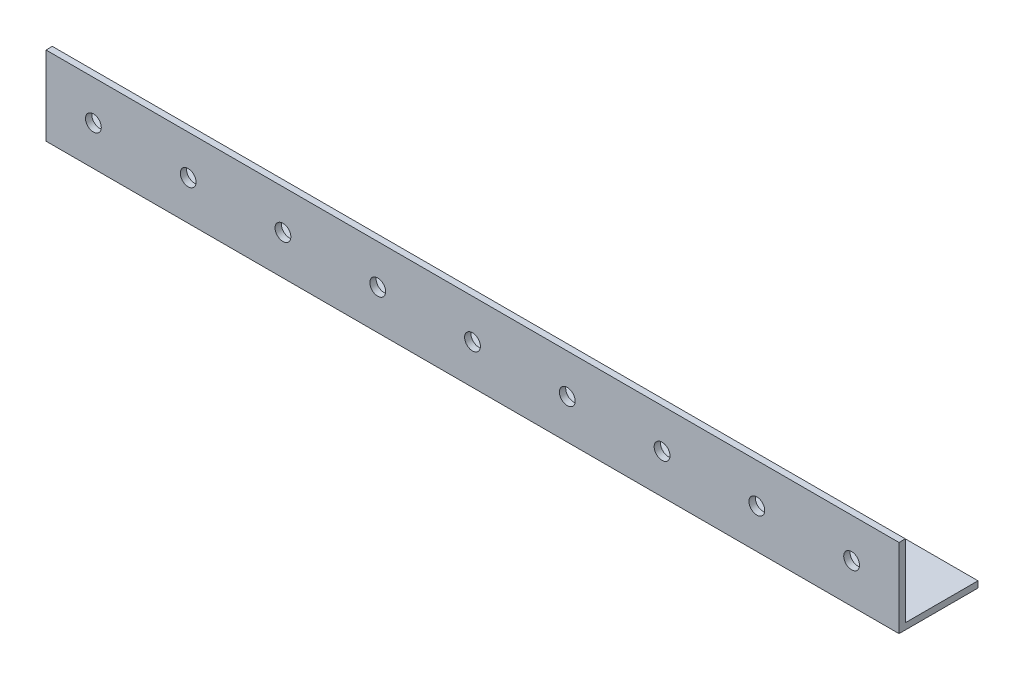
from build123d import *

# Parameters (mm, degrees)
EXTRUDE_1_DEPTH     = 540
SKETCH_2_R          = 5
CUT_EXTRUDE_1_DEPTH = 51
SKETCH_3_R          = 5
CUT_EXTRUDE_2_DEPTH = 51


with BuildPart() as part:
    # Эскиз1 → Вытянуть-Тонкостенный1 (new body)
    with BuildSketch(Plane(origin=(0, 0, 0), x_dir=(0, 0, -1), z_dir=(1, 0, 0))):
        Polygon((50, 0), (0, 0), (0, 50), (4, 50), (4, 4), (50, 4), align=None)
    extrude(amount=EXTRUDE_1_DEPTH)

    # Эскиз2 → Вырез-Вытянуть1 (cut, through all)
    with BuildSketch(Plane.XY):
        with Locations((30, 25)):
            Circle(SKETCH_2_R)
        with Locations((90, 25)):
            Circle(SKETCH_2_R)
        with Locations((150, 25)):
            Circle(SKETCH_2_R)
        with Locations((210, 25)):
            Circle(SKETCH_2_R)
        with Locations((270, 25)):
            Circle(SKETCH_2_R)
        with Locations((330, 25)):
            Circle(SKETCH_2_R)
        with Locations((390, 25)):
            Circle(SKETCH_2_R)
        with Locations((450, 25)):
            Circle(SKETCH_2_R)
        with Locations((510, 25)):
            Circle(SKETCH_2_R)
    extrude(amount=-CUT_EXTRUDE_1_DEPTH, mode=Mode.SUBTRACT)

    # Эскиз3 → Вырез-Вытянуть2 (cut, through all)
    with BuildSketch(Plane.XZ):
        with Locations((30, -25)):
            Circle(SKETCH_3_R)
        with Locations((90, -25)):
            Circle(SKETCH_3_R)
        with Locations((150, -25)):
            Circle(SKETCH_3_R)
        with Locations((210, -25)):
            Circle(SKETCH_3_R)
        with Locations((270, -25)):
            Circle(SKETCH_3_R)
        with Locations((330, -25)):
            Circle(SKETCH_3_R)
        with Locations((390, -25)):
            Circle(SKETCH_3_R)
        with Locations((450, -25)):
            Circle(SKETCH_3_R)
        with Locations((510, -25)):
            Circle(SKETCH_3_R)
    extrude(amount=-CUT_EXTRUDE_2_DEPTH, mode=Mode.SUBTRACT)


solid = part.part
